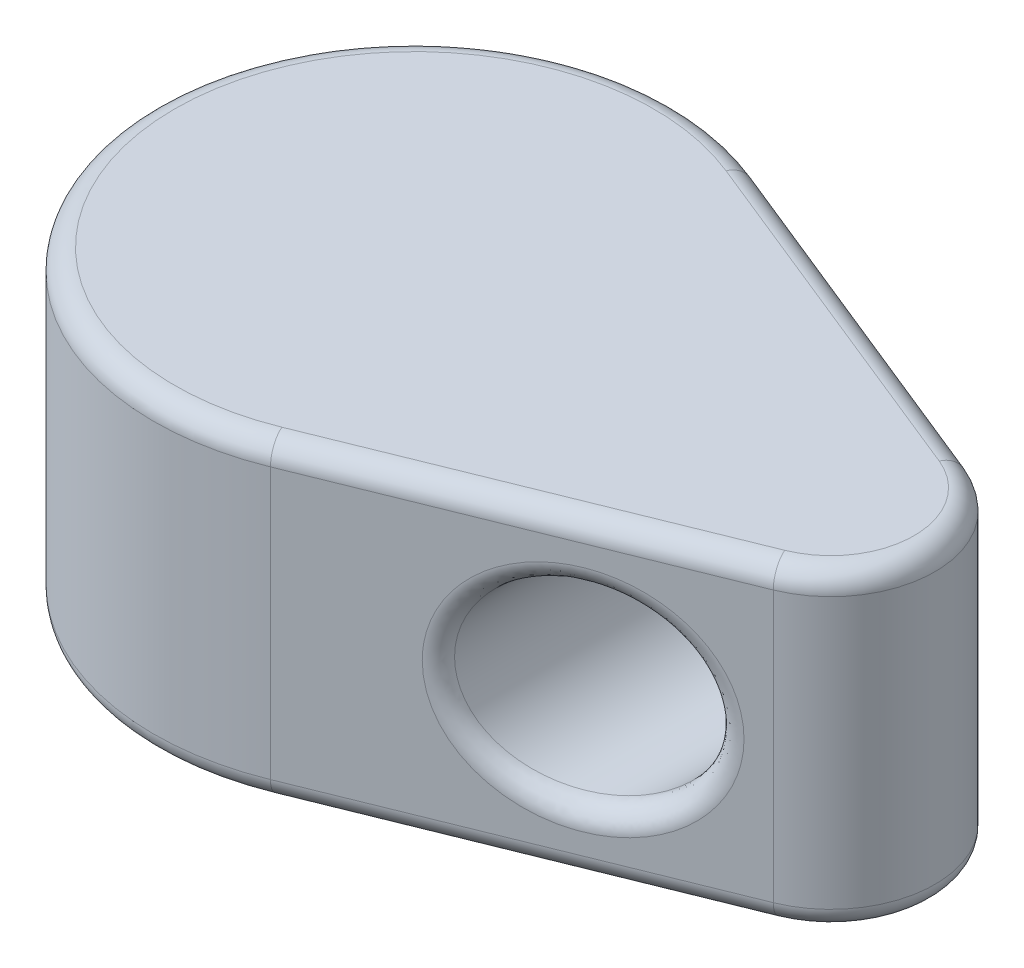
from build123d import *

# Parameters (mm, degrees)
SKETCH1_R               = 1.016
BOSS_EXTRUDE1_DEPTH     = 7.62
SKETCH2_R               = 1.016
BOSS_EXTRUDE2_DEPTH     = 1.5875
SKETCH3_R               = 2.286
CUT_EXTRUDE1_DEPTH      = 7.35
CUT_EXTRUDE1_DEPTH_BACK = 7.35
FILLET1_R               = 0.508
FILLET2_R               = 0.127


with BuildPart() as part:
    # Sketch1 → Boss-Extrude1 (new body)
    with BuildSketch(Plane(origin=(0, 0, 0), x_dir=(1, 0, 0), z_dir=(0, 1, 0))):
        with BuildLine():
            Line((11.1125, 2.35464302), (2.38125, 5.886607549))
            ThreePointArc((2.38125, 5.886607549), (-6.35, 0), (2.38125, -5.886607549))
            Line((2.38125, -5.886607549), (11.1125, -2.35464302))
            ThreePointArc((11.1125, -2.35464302), (12.7, 0), (11.1125, 2.35464302))
        make_face()
        Circle(SKETCH1_R, mode=Mode.SUBTRACT)
    extrude(amount=BOSS_EXTRUDE1_DEPTH)

    # Sketch2 → Boss-Extrude2 (add)
    with BuildSketch(Plane(origin=(0, 7.62, 0), x_dir=(1, 0, 0), z_dir=(0, 1, 0))):
        Circle(SKETCH2_R)
    extrude(amount=-BOSS_EXTRUDE2_DEPTH)

    # Sketch3 → Cut-Extrude1 (cut, two sides)
    with BuildSketch(Plane.XY) as cut_extrude1_sk:
        with Locations((7.62, 3.81)):
            Circle(SKETCH3_R)
    extrude(amount=CUT_EXTRUDE1_DEPTH, mode=Mode.SUBTRACT)
    extrude(cut_extrude1_sk.sketch, amount=-CUT_EXTRUDE1_DEPTH_BACK, mode=Mode.SUBTRACT)

    # Fillet1
    fillet1_edges = [part.edges().sort_by_distance(p)[0] for p in [
        (6.746875, 0, -4.120625284),
        (6.746875, 7.62, -4.120625284),
        (5.334, 3.809986249, -4.692161363),
        (5.334, 3.810013751, 4.692161363),
        (6.746875, 0, 4.120625284),
        (6.746875, 7.62, 4.120625284),
        (-6.35, 0, 0),
        (-6.35, 7.62, 0),
        (12.7, 7.62, 0),
        (12.7, 0, 0),
    ]]
    fillet(fillet1_edges, radius=FILLET1_R)

    # Fillet2
    fillet2_edges = [part.edges().sort_by_distance(p)[0] for p in [
        (-1.016, 0, 0),
    ]]
    fillet(fillet2_edges, radius=FILLET2_R)


solid = part.part
